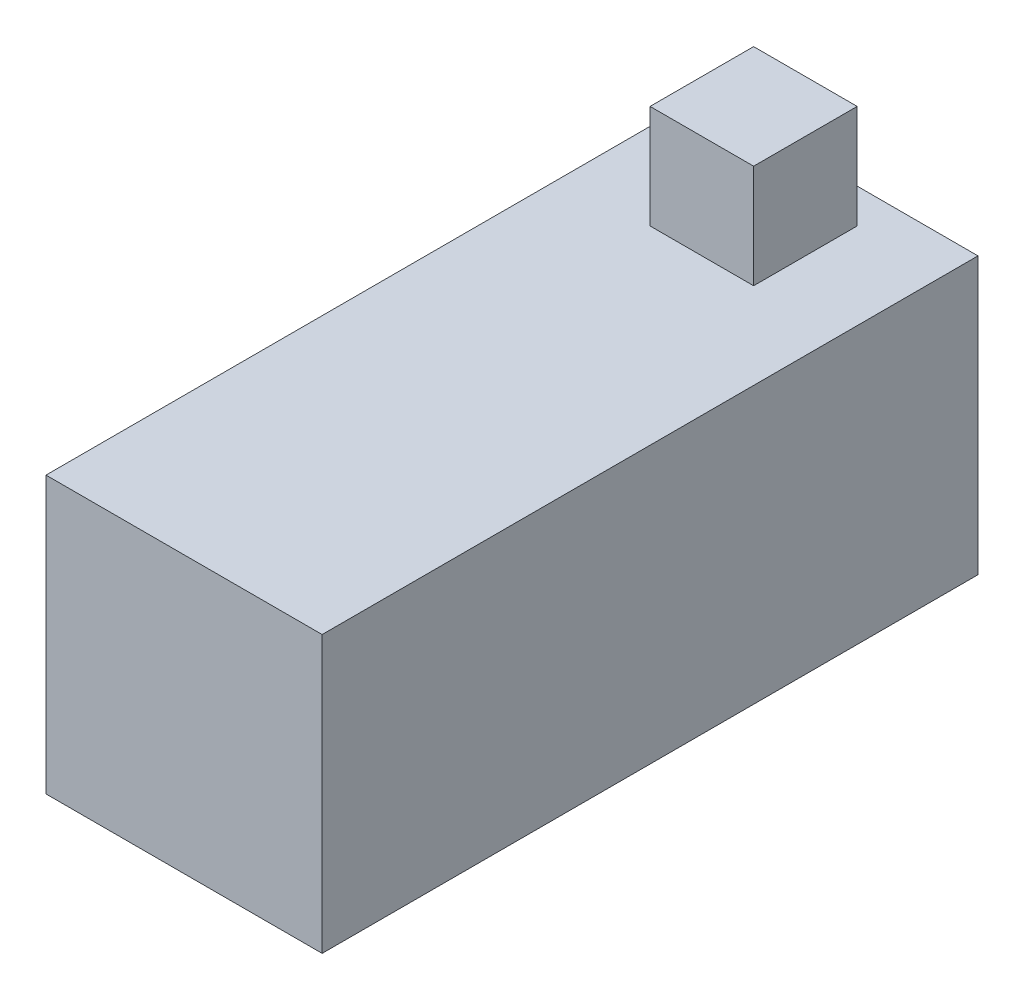
from build123d import *

# Parameters (mm, degrees)
SKETCH2_W           = 8
SKETCH2_H           = 19
BOSS_EXTRUDE1_DEPTH = 8
SKETCH2_3_W         = 3
SKETCH2_3_H         = 3
BOSS_EXTRUDE2_DEPTH = 3
SKETCH3_R           = 3.5
CUT_EXTRUDE1_DEPTH  = 1


with BuildPart() as part:
    # Sketch2 → Boss-Extrude1 (new body)
    with BuildSketch(Plane(origin=(0, 0, 0), x_dir=(1, 0, 0), z_dir=(0, 1, 0))):
        Rectangle(SKETCH2_W, SKETCH2_H)
    extrude(amount=-BOSS_EXTRUDE1_DEPTH)

    # Sketch2_3 → Boss-Extrude2 (add)
    with BuildSketch(Plane(origin=(0, 0, 0), x_dir=(1, 0, 0), z_dir=(0, 1, 0))):
        with Locations((0, 7)):
            Rectangle(SKETCH2_3_W, SKETCH2_3_H)
    extrude(amount=BOSS_EXTRUDE2_DEPTH)

    # Sketch3 → Cut-Extrude1 (cut)
    with BuildSketch(Plane(origin=(0, 0, -9.5), x_dir=(-1, 0, 0), z_dir=(0, 0, -1))):
        with Locations((0, -4)):
            Circle(SKETCH3_R)
    extrude(amount=-CUT_EXTRUDE1_DEPTH, mode=Mode.SUBTRACT)


solid = part.part
